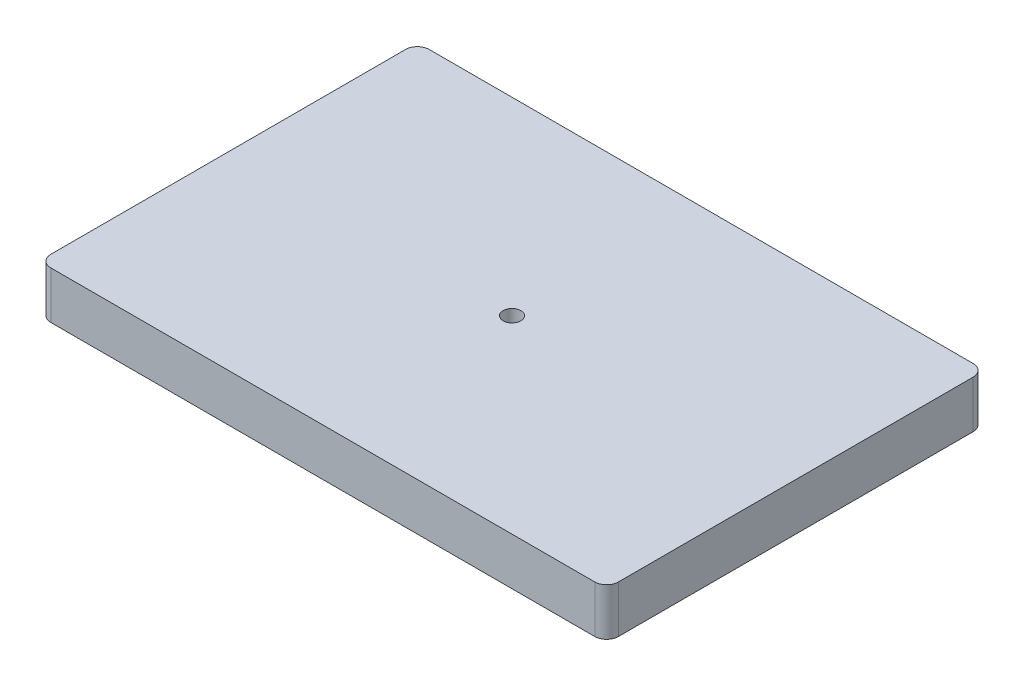
from build123d import *

# Parameters (mm, degrees)
BOSS_EXTRUDE1_DEPTH = 12.7
CUT_EXTRUDE1_START  = 12.7
SKETCH2_R           = 2.38125
CUT_EXTRUDE1_DEPTH  = 13.7


with BuildPart() as part:
    # Sketch1 → Boss-Extrude1 (new body)
    with BuildSketch(Plane(origin=(0, 0, 0), x_dir=(1, 0, 0), z_dir=(0, 1, 0))):
        with BuildLine():
            Line((-73.025, 50.8), (73.025, 50.8))
            ThreePointArc((73.025, 50.8), (75.27006403, 49.87006403), (76.2, 47.625))
            Line((76.2, 47.625), (76.2, -47.625))
            ThreePointArc((76.2, -47.625), (75.27006403, -49.87006403), (73.025, -50.8))
            Line((73.025, -50.8), (-73.025, -50.8))
            ThreePointArc((-73.025, -50.8), (-75.27006403, -49.87006403), (-76.2, -47.625))
            Line((-76.2, -47.625), (-76.2, 47.625))
            ThreePointArc((-76.2, 47.625), (-75.27006403, 49.87006403), (-73.025, 50.8))
        make_face()
    extrude(amount=BOSS_EXTRUDE1_DEPTH)

    # Sketch2 → Cut-Extrude1 (cut, through all)
    with BuildSketch(Plane(origin=(0, 0, 0), x_dir=(1, 0, 0), z_dir=(0, 1, 0)).offset(CUT_EXTRUDE1_START)):
        Circle(SKETCH2_R)
    extrude(amount=-CUT_EXTRUDE1_DEPTH, mode=Mode.SUBTRACT)


solid = part.part
